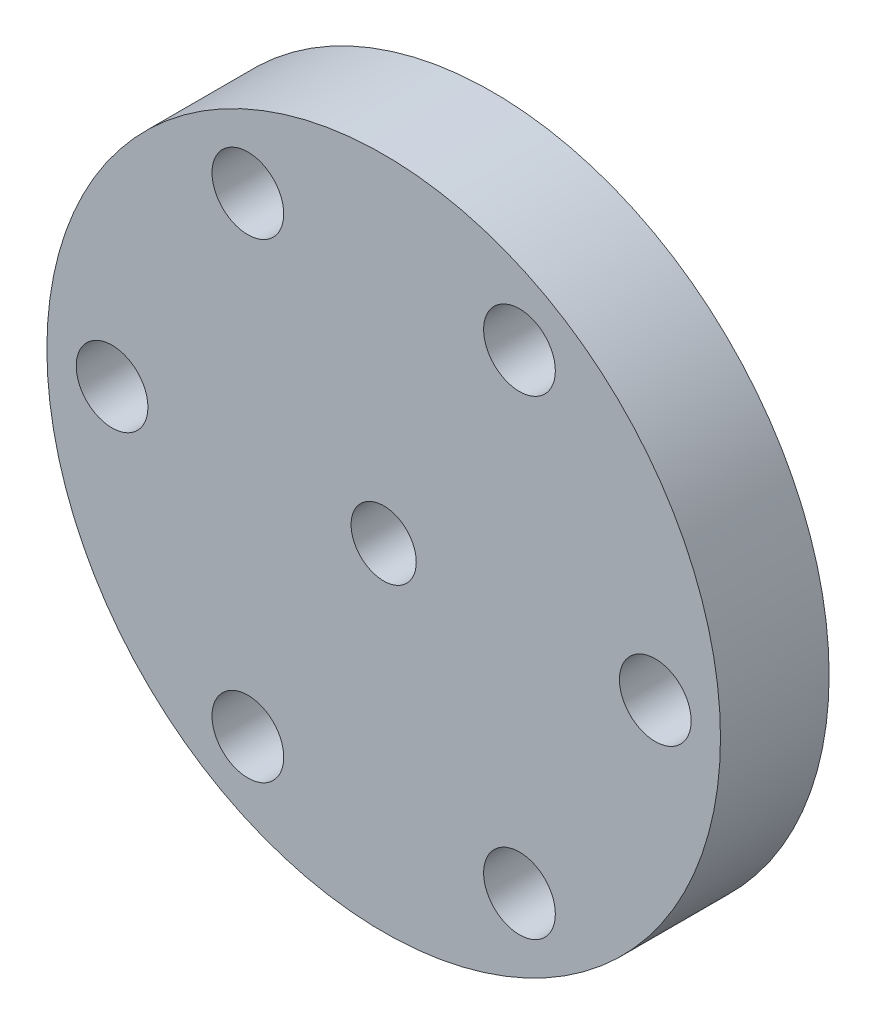
from build123d import *

# Parameters (mm, degrees)
ESBO_O2_W                = 80
ESBO_O2_H                = 117.2
RESSALTO_EXTRUS_O2_DEPTH = 5
ESBO_O3_R                = 3
CORTE_EXTRUS_O1_DEPTH    = 11
ESBO_O4_R                = 3.3
CORTE_EXTRUS_O2_DEPTH    = 34.5
PADR_OCIRCULAR1_COUNT    = 6
ESBO_O12_W               = 80
ESBO_O12_H               = 17.2
CORTE_EXTRUS_O7_DEPTH    = 11
ESBO_O13_W               = 80
ESBO_O13_H               = 100
ESBO_O13_R               = 31
CORTE_EXTRUS_O8_DEPTH    = 11


with BuildPart() as part:
    # Esboço2 → Ressalto-extrusão2 (new body, symmetric)
    with BuildSketch(Plane.XY):
        Rectangle(ESBO_O2_W, ESBO_O2_H)
    extrude(amount=RESSALTO_EXTRUS_O2_DEPTH, both=True)

    # Esboço3 → Corte-extrusão1 (cut, through all)
    with BuildSketch(Plane.XY.offset(5)):
        Circle(ESBO_O3_R)
    extrude(amount=-CORTE_EXTRUS_O1_DEPTH, mode=Mode.SUBTRACT)

    # Esboço4 → Corte-extrusão2 (cut)
    with BuildSketch(Plane.XY.offset(5)):
        with Locations((12.5, 21.650635095)):
            Circle(ESBO_O4_R)
    corte_extrus_o2 = extrude(amount=-CORTE_EXTRUS_O2_DEPTH, mode=Mode.SUBTRACT)

    # PadrãoCircular1: Corte-extrusão2 ×6 about axis
    padr_ocircular1_axis = Axis((0, 0, 0), (0, 0, 1))
    for i in range(1, PADR_OCIRCULAR1_COUNT):
        add(corte_extrus_o2.rotate(padr_ocircular1_axis, i * 360 / PADR_OCIRCULAR1_COUNT), mode=Mode.SUBTRACT)

    # Esboço12 → Corte-extrusão7 (cut, through all)
    with BuildSketch(Plane.XY.offset(5)):
        with Locations((0, -50)):
            Rectangle(ESBO_O12_W, ESBO_O12_H)
    extrude(amount=-CORTE_EXTRUS_O7_DEPTH, mode=Mode.SUBTRACT)

    # Esboço13 → Corte-extrusão8 (cut, through all)
    with BuildSketch(Plane.XY.offset(5)):
        with Locations((0, 8.6)):
            Rectangle(ESBO_O13_W, ESBO_O13_H)
        Circle(ESBO_O13_R, mode=Mode.SUBTRACT)
    extrude(amount=-CORTE_EXTRUS_O8_DEPTH, mode=Mode.SUBTRACT)


solid = part.part
